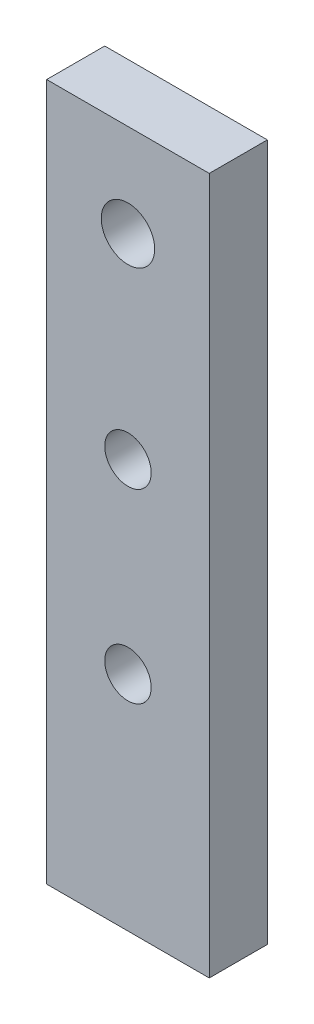
from build123d import *

# Parameters (mm, degrees)
SKETCH3_W           = 8.89
SKETCH3_H           = 3.175
BOSS_EXTRUDE2_DEPTH = 38.1
SKETCH4_R           = 1.4605
SKETCH4_R_2         = 1.27
CUT_EXTRUDE1_DEPTH  = 40.25204103


with BuildPart() as part:
    # Sketch3 → Boss-Extrude2 (new body)
    with BuildSketch(Plane(origin=(0, 0, 0), x_dir=(1, 0, 0), z_dir=(0, 1, 0))):
        with Locations((4.445, -5.1435)):
            Rectangle(SKETCH3_W, SKETCH3_H)
    extrude(amount=BOSS_EXTRUDE2_DEPTH)

    # Sketch4 → Cut-Extrude1 (cut, through all)
    with BuildSketch(Plane.XY.offset(6.731)):
        with Locations((4.445, 33.02)):
            Circle(SKETCH4_R)
        with Locations((4.445, 12.169083682)):
            Circle(SKETCH4_R_2)
        with Locations((4.445, 22.329083682)):
            Circle(SKETCH4_R_2)
    extrude(amount=-CUT_EXTRUDE1_DEPTH, mode=Mode.SUBTRACT)


solid = part.part
